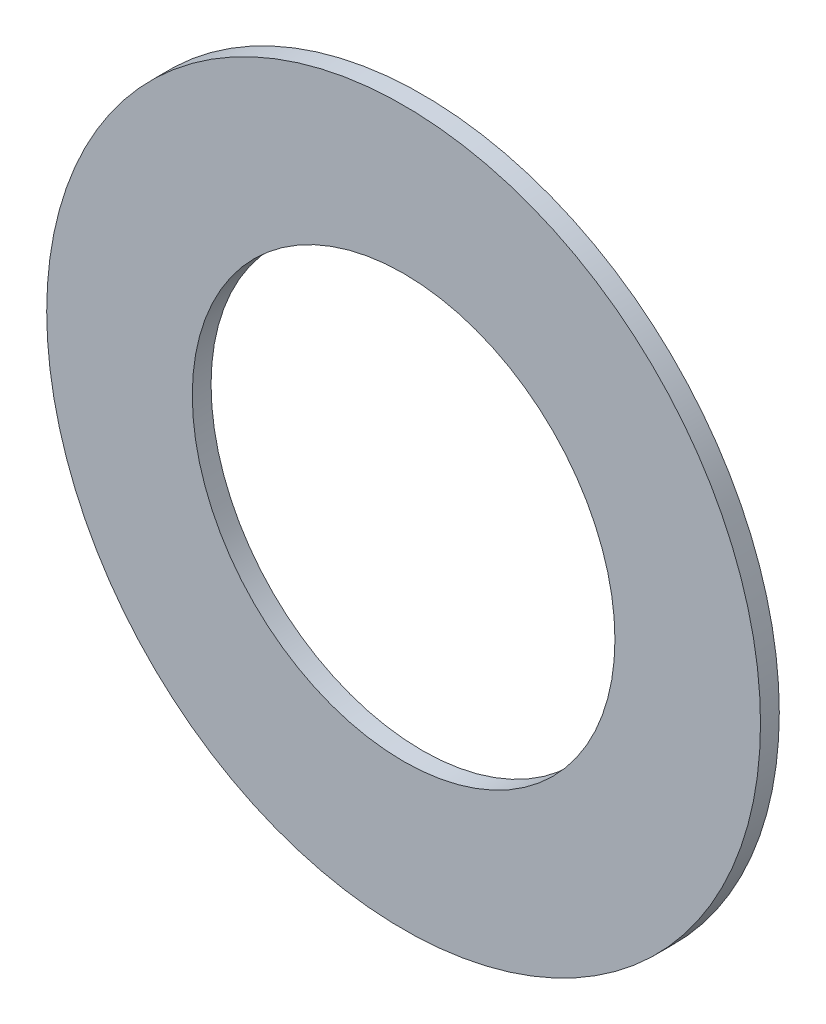
from build123d import *

# Parameters (mm, degrees)
SCHIZZO1_R                   = 19
SCHIZZO1_R_2                 = 11.25
ESTRUSIONE_ESTRUSIONE1_DEPTH = 1


with BuildPart() as part:
    # Schizzo1 → Estrusione-Estrusione1 (new body)
    with BuildSketch(Plane.XY):
        Circle(SCHIZZO1_R)
        Circle(SCHIZZO1_R_2, mode=Mode.SUBTRACT)
    extrude(amount=ESTRUSIONE_ESTRUSIONE1_DEPTH)


solid = part.part
